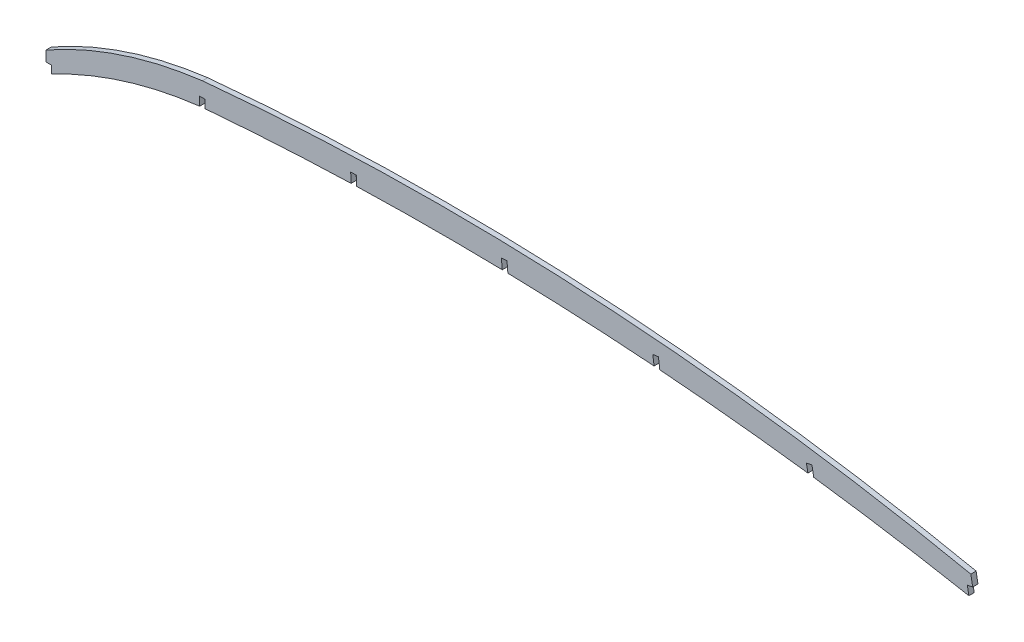
from build123d import *

# Parameters (mm, degrees)
BOSS_EXTRUDE1_DEPTH = 3.175
CUT_EXTRUDE1_DEPTH  = 577.346072705


with BuildPart() as part:
    # Sketch1 → Boss-Extrude1 (new body)
    with BuildSketch(Plane.XY):
        with BuildLine():
            Line((557.916984218, 99.326538403), (555.638244479, 111.822940833))
            ThreePointArc((555.638244479, 111.822940833), (325.782502236, 142.132503557), (93.98, 137.668))
            ThreePointArc((93.98, 137.668), (45.466310815, 126.795024577), (0, 106.68))
            Line((0, 106.68), (0, 93.98))
            ThreePointArc((0, 93.98), (45.52945751, 113.491169294), (93.98, 123.794671649))
            ThreePointArc((93.98, 123.794671649), (326.784483289, 127.411721364), (557.916984218, 99.326538403))
        make_face()
    extrude(amount=-BOSS_EXTRUDE1_DEPTH)

    # Sketch2 → Cut-Extrude1 (cut, through all)
    with BuildSketch(Plane.XY):
        with BuildLine():
            Line((553.540722528, 105.060688054), (554.466577904, 99.983384814))
            ThreePointArc((554.466577904, 99.983384814), (556.191949942, 99.655848737), (557.916984218, 99.326538403))
            Line((557.916984218, 99.326538403), (556.764166066, 105.64848878))
            Line((556.764166066, 105.64848878), (553.540722528, 105.060688054))
        make_face()
        with BuildLine():
            Line((456.854976279, 120.249363717), (457.732770479, 115.435623412))
            ThreePointArc((457.732770479, 115.435623412), (459.492028195, 115.205203914), (461.251045548, 114.972956616))
            Line((461.251045548, 114.972956616), (460.178373044, 120.855391093))
            Line((460.178373044, 120.855391093), (456.854976279, 120.249363717))
        make_face()
        with BuildLine():
            Line((364.577933431, 130.603714492), (365.330558588, 124.941352647))
            ThreePointArc((365.330558587, 124.941352647), (367.052077733, 124.810582409), (368.773463785, 124.678071721))
            Line((368.773463785, 124.678071721), (367.926681813, 131.048820676))
            Line((367.926681813, 131.048820676), (364.577933431, 130.603714492))
        make_face()
        with BuildLine():
            Line((273.590830142, 135.268456112), (274.098105393, 129.375373235))
            ThreePointArc((274.098105393, 129.375373235), (274.149189345, 129.374257883), (274.200273264, 129.373141002))
            Line((274.200273264, 129.373141002), (273.698590918, 135.20125036))
            Line((273.698590918, 135.20125036), (276.861892945, 135.473546675))
            Line((276.861892945, 135.473546675), (277.393285078, 129.300294826))
            ThreePointArc((277.393285078, 129.300294826), (277.44437754, 129.299080619), (277.495469966, 129.297864882))
            Line((277.495469966, 129.297864882), (276.956583497, 135.558179406))
            Line((276.956583497, 135.558179406), (273.590830142, 135.268456112))
        make_face()
        with BuildLine():
            Line((183.054551015, 134.687145422), (183.294622405, 128.941721131))
            ThreePointArc((183.294622405, 128.941721131), (184.983027134, 128.993862208), (186.671482616, 129.044333071))
            Line((186.671482616, 129.044333071), (186.429805755, 134.828179757))
            Line((186.429805755, 134.828179757), (183.054551015, 134.687145422))
        make_face()
        with BuildLine():
            Line((92.2909, 128.848746884), (92.2909, 123.599182896))
            ThreePointArc((92.2909, 123.599182896), (93.135286415, 123.698340713), (93.98, 123.794671649))
            ThreePointArc((93.98, 123.794671649), (94.824532509, 123.865366756), (95.6691, 123.93564272))
            Line((95.6691, 123.93564272), (95.6691, 128.848746884))
            Line((95.6691, 128.848746884), (92.2909, 128.848746884))
        make_face()
        with BuildLine():
            Line((0, 100.457), (0, 93.98))
            ThreePointArc((0, 93.98), (1.673005931, 94.891313671), (3.3528, 95.790053532))
            Line((3.3528, 95.790053532), (3.3528, 100.457))
            Line((3.3528, 100.457), (0, 100.457))
        make_face()
    extrude(amount=-CUT_EXTRUDE1_DEPTH, mode=Mode.SUBTRACT)


with BuildPart() as cut_extrude1_kept_piece:
    # of the separate pieces the step leaves, the one the design keeps (cut_extrude1_pieces_kept)
    add(part.part.solids().sort_by_distance((556.764166066, 105.64848878, 0))[0])


solid = cut_extrude1_kept_piece.part
